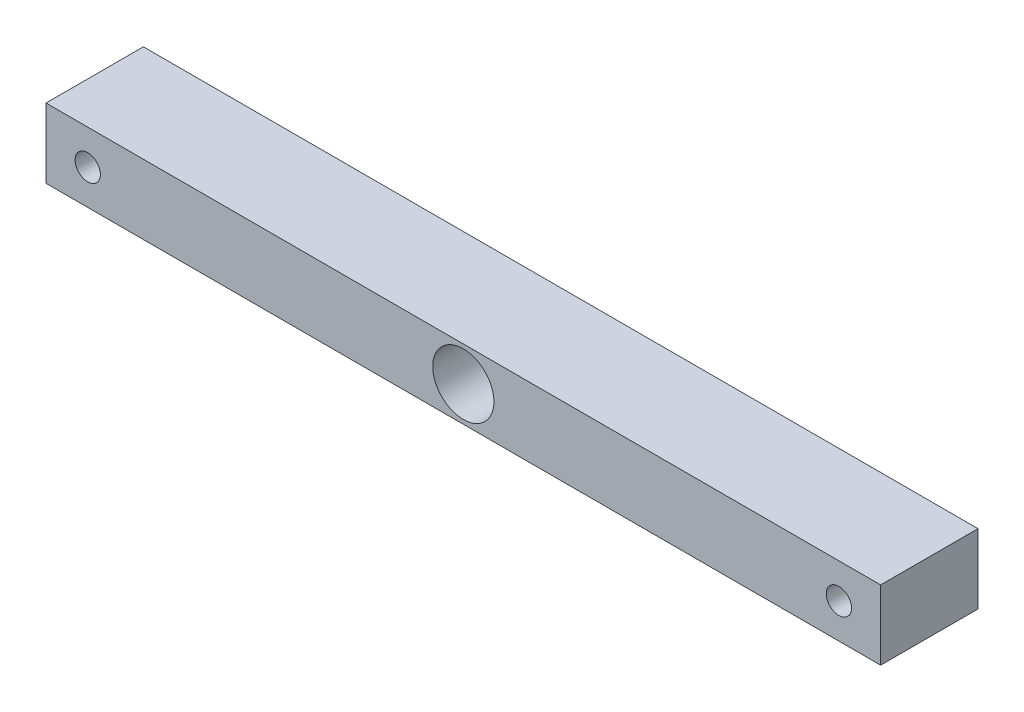
from build123d import *

# Parameters (mm, degrees)
SKETCH1_W           = 300
SKETCH1_H           = 25
BOSS_EXTRUDE1_DEPTH = 35
SKETCH2_R           = 4.542391588
SKETCH2_R_2         = 11
CUT_EXTRUDE1_DEPTH  = 36


with BuildPart() as part:
    # Sketch1 → Boss-Extrude1 (new body)
    with BuildSketch(Plane.XY):
        Rectangle(SKETCH1_W, SKETCH1_H)
    extrude(amount=BOSS_EXTRUDE1_DEPTH)

    # Sketch2 → Cut-Extrude1 (cut, through all)
    with BuildSketch(Plane.XY.offset(35)):
        with Locations((-135, 0)):
            Circle(SKETCH2_R)
        Circle(SKETCH2_R_2)
        with Locations((135, 0)):
            Circle(SKETCH2_R)
    extrude(amount=-CUT_EXTRUDE1_DEPTH, mode=Mode.SUBTRACT)


solid = part.part
